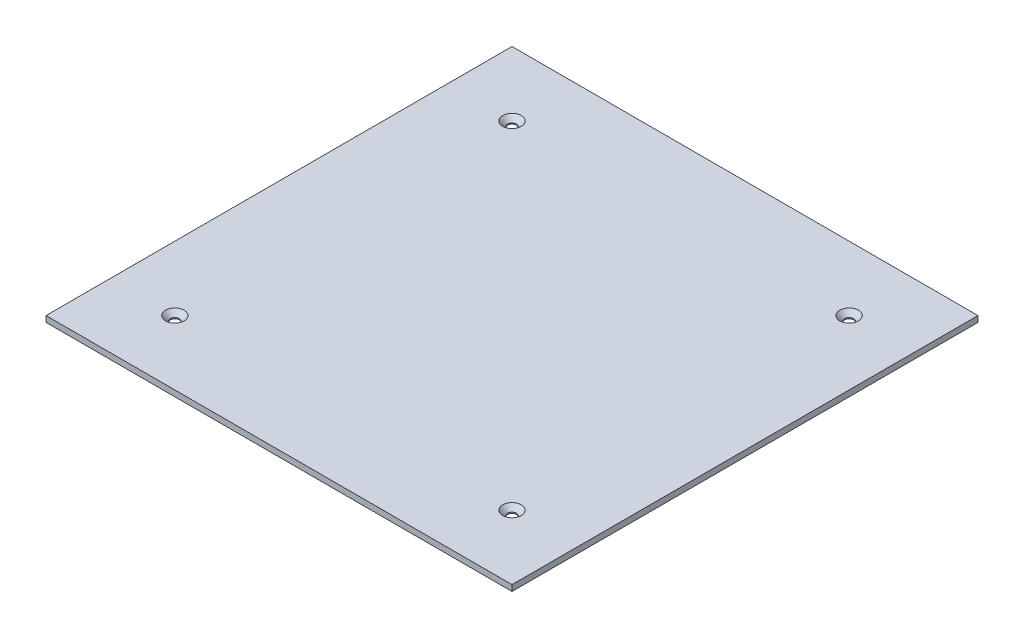
from build123d import *

# Parameters (mm, degrees)
SKETCH1_W                                      = 235
SKETCH1_H                                      = 235
BOSS_EXTRUDE1_DEPTH                            = 3
CSK_FOR_M4_FLAT_HEAD_MACHINE_SCREW1_AT_2_COUNT = 2
CSK_FOR_M4_FLAT_HEAD_MACHINE_SCREW1_AT_2_PITCH = 170
CSK_FOR_M4_FLAT_HEAD_MACHINE_SCREW1_AT_3_COUNT = 2
CSK_FOR_M4_FLAT_HEAD_MACHINE_SCREW1_AT_3_PITCH = 240.416305603
CSK_FOR_M4_FLAT_HEAD_MACHINE_SCREW1_AT_4_COUNT = 2
CSK_FOR_M4_FLAT_HEAD_MACHINE_SCREW1_AT_4_PITCH = 170
SKETCH9_W                                      = 10
SKETCH9_H                                      = 12
SKETCH9_W_2                                    = 17
SKETCH9_H_2                                    = 20
BOSS_EXTRUDE5_DEPTH                            = 15


with BuildPart() as part:
    # Sketch1 → Boss-Extrude1 (new body)
    with BuildSketch(Plane(origin=(0, 0, 0), x_dir=(1, 0, 0), z_dir=(0, 1, 0))):
        Rectangle(SKETCH1_W, SKETCH1_H)
    extrude(amount=BOSS_EXTRUDE1_DEPTH)

    # Sketch3 → CSK for M4 Flat Head Machine Screw1 (revolve, cut)
    with BuildSketch(Plane(origin=(-85, 3, -85), x_dir=(0, 0, 1), z_dir=(1, 0, 0))):
        Polygon((0, 0), (0, 3), (2.25, 3), (2.25, 2.45), (4.7, 0), align=None)
    csk_for_m4_flat_head_machine_screw1 = revolve(axis=Axis((-85, 9.35, -85), (0, -1, 0)), mode=Mode.SUBTRACT)

    # CSK for M4 Flat Head Machine Screw1 at 2: CSK for M4 Flat Head Machine Screw1 ×2
    with Locations(*[(i * CSK_FOR_M4_FLAT_HEAD_MACHINE_SCREW1_AT_2_PITCH, 0, 0) for i in range(1, CSK_FOR_M4_FLAT_HEAD_MACHINE_SCREW1_AT_2_COUNT)]):
        add(csk_for_m4_flat_head_machine_screw1, mode=Mode.SUBTRACT)

    # CSK for M4 Flat Head Machine Screw1 at 3: CSK for M4 Flat Head Machine Screw1 ×2
    with Locations(*[Vector(0.707106781, 0, 0.707106781) * (i * CSK_FOR_M4_FLAT_HEAD_MACHINE_SCREW1_AT_3_PITCH) for i in range(1, CSK_FOR_M4_FLAT_HEAD_MACHINE_SCREW1_AT_3_COUNT)]):
        add(csk_for_m4_flat_head_machine_screw1, mode=Mode.SUBTRACT)

    # CSK for M4 Flat Head Machine Screw1 at 4: CSK for M4 Flat Head Machine Screw1 ×2
    with Locations(*[(0, 0, i * CSK_FOR_M4_FLAT_HEAD_MACHINE_SCREW1_AT_4_PITCH) for i in range(1, CSK_FOR_M4_FLAT_HEAD_MACHINE_SCREW1_AT_4_COUNT)]):
        add(csk_for_m4_flat_head_machine_screw1, mode=Mode.SUBTRACT)

    # Sketch9 → Boss-Extrude5 (add)
    with BuildSketch(Plane.XZ):
        with Locations((-64.5, -103.5)):
            Rectangle(SKETCH9_W, SKETCH9_H)
        with Locations((-44, -105.5)):
            Rectangle(SKETCH9_W_2, SKETCH9_H_2)
    extrude(amount=BOSS_EXTRUDE5_DEPTH)


solid = part.part
